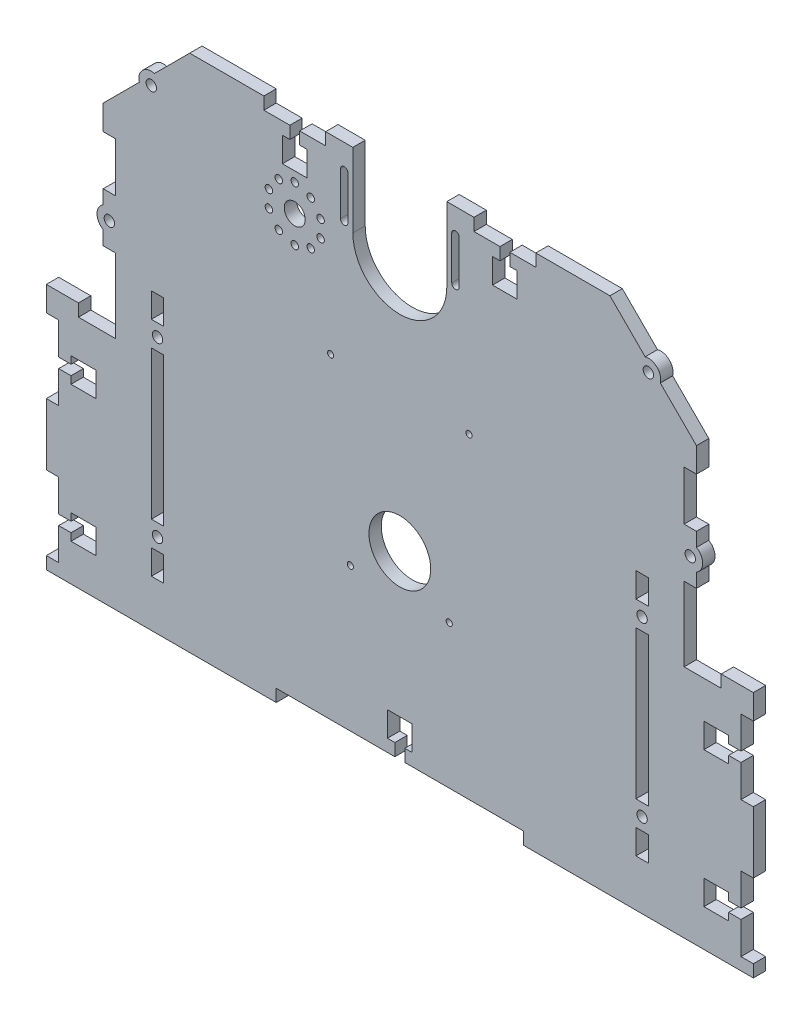
from build123d import *

# Parameters (mm, degrees)
SKETCH1_W           = 240
SKETCH1_H           = 210
BOSS_EXTRUDE1_DEPTH = 5
SKETCH2_W           = 5
SKETCH2_H           = 10
SKETCH2_H_2         = 60
CUT_EXTRUDE1_DEPTH  = 5
SKETCH3_W           = 5
SKETCH3_H           = 20
SKETCH3_H_2         = 25
CUT_EXTRUDE2_DEPTH  = 10
CUT_EXTRUDE3_DEPTH  = 10
SKETCH5_W           = 25
SKETCH5_H           = 5
CUT_EXTRUDE4_DEPTH  = 10
SKETCH7_R           = 2.1
CUT_EXTRUDE6_DEPTH  = 5
BOSS_EXTRUDE2_DEPTH = 5
SKETCH9_R           = 2.1
CUT_EXTRUDE7_DEPTH  = 5
SKETCH10_R          = 2.1
CUT_EXTRUDE8_DEPTH  = 5
BOSS_EXTRUDE3_DEPTH = 5
SKETCH13_R          = 2.1
CUT_EXTRUDE9_DEPTH  = 5
SKETCH14_R          = 1.25
CUT_EXTRUDE10_DEPTH = 5
SKETCH22_R          = 19
CUT_EXTRUDE16_DEPTH = 5
BOSS_EXTRUDE4_DEPTH = 5
SKETCH26_W          = 23
SKETCH26_H          = 100
BOSS_EXTRUDE5_DEPTH = 5
SKETCH27_W          = 5
SKETCH27_H          = 30
CUT_EXTRUDE19_DEPTH = 5
SKETCH29_W          = 5
SKETCH29_H          = 5
CUT_EXTRUDE20_DEPTH = 5
SKETCH31_W          = 10
SKETCH31_H          = 5
CUT_EXTRUDE21_DEPTH = 5
SKETCH32_W          = 286
SKETCH32_H          = 5
BOSS_EXTRUDE7_DEPTH = 1
SKETCH33_W          = 286
SKETCH33_H          = 5
CUT_EXTRUDE22_DEPTH = 1
SKETCH35_W          = 5
SKETCH35_H          = 4
CUT_EXTRUDE24_DEPTH = 5
SKETCH37_R          = 2.1
CUT_EXTRUDE25_DEPTH = 5
SKETCH38_R          = 2.1
BOSS_EXTRUDE8_DEPTH = 5
SKETCH39_W          = 4
SKETCH39_H          = 5
SKETCH39_W_2        = 10
SKETCH39_H_2        = 10
CUT_EXTRUDE26_DEPTH = 5
SKETCH40_W          = 100
SKETCH40_H          = 5
CUT_EXTRUDE27_DEPTH = 5
SKETCH41_R          = 2.1
SKETCH41_W          = 5
SKETCH41_H          = 10
SKETCH41_H_2        = 60
BOSS_EXTRUDE9_DEPTH = 5
CUT_EXTRUDE28_DEPTH = 5
SKETCH43_W          = 4
SKETCH43_H          = 5
CUT_EXTRUDE29_DEPTH = 5
SKETCH44_R          = 4.25
SKETCH44_R_2        = 1.5
CUT_EXTRUDE30_DEPTH = 10
SKETCH45_R          = 12.5
CUT_EXTRUDE31_DEPTH = 10


with BuildPart() as part:
    # Sketch1 → Boss-Extrude1 (new body)
    with BuildSketch(Plane.XY):
        with Locations((-120, 105)):
            Rectangle(SKETCH1_W, SKETCH1_H)
    extrude(amount=BOSS_EXTRUDE1_DEPTH)

    # Sketch2 → Cut-Extrude1 (cut)
    with BuildSketch(Plane.XY.offset(5)):
        with Locations((-218, 24)):
            Rectangle(SKETCH2_W, SKETCH2_H)
        with Locations((-218, 69)):
            Rectangle(SKETCH2_W, SKETCH2_H_2)
        with Locations((-218, 114)):
            Rectangle(SKETCH2_W, SKETCH2_H)
        with Locations((-203, 24)):
            Rectangle(SKETCH2_W, SKETCH2_H)
        with Locations((-203, 69)):
            Rectangle(SKETCH2_W, SKETCH2_H_2)
        with Locations((-203, 114)):
            Rectangle(SKETCH2_W, SKETCH2_H)
        with Locations((-37, 114)):
            Rectangle(SKETCH2_W, SKETCH2_H)
        with Locations((-37, 69)):
            Rectangle(SKETCH2_W, SKETCH2_H_2)
        with Locations((-37, 24)):
            Rectangle(SKETCH2_W, SKETCH2_H)
        with Locations((-22, 114)):
            Rectangle(SKETCH2_W, SKETCH2_H)
        with Locations((-22, 69)):
            Rectangle(SKETCH2_W, SKETCH2_H_2)
        with Locations((-22, 24)):
            Rectangle(SKETCH2_W, SKETCH2_H)
    extrude(amount=-CUT_EXTRUDE1_DEPTH, mode=Mode.SUBTRACT)

    # Sketch3 → Cut-Extrude2 (cut)
    with BuildSketch(Plane.XY.offset(5)):
        with Locations((-237.5, 195)):
            Rectangle(SKETCH3_W, SKETCH3_H)
        with Locations((-237.5, 155)):
            Rectangle(SKETCH3_W, SKETCH3_H)
        with Locations((-237.5, 112.5)):
            Rectangle(SKETCH3_W, SKETCH3_H_2)
        with Locations((-2.5, 112.5)):
            Rectangle(SKETCH3_W, SKETCH3_H_2)
        with Locations((-2.5, 155)):
            Rectangle(SKETCH3_W, SKETCH3_H)
        with Locations((-2.5, 195)):
            Rectangle(SKETCH3_W, SKETCH3_H)
    extrude(amount=-CUT_EXTRUDE2_DEPTH, mode=Mode.SUBTRACT)

    # Sketch4 → Cut-Extrude3 (cut)
    with BuildSketch(Plane.XY.offset(5)):
        Polygon((-235, 180), (-240, 175), (-240, 210), (-205, 210), (-210, 205), (-235, 205), align=None)
        Polygon((-235, 205), (-235, 180), (-210, 205), align=None)
        Polygon((-30, 205), (-5, 205), (-5, 180), align=None)
        Polygon((-30, 205), (-35, 210), (0, 210), (0, 175), (-5, 180), (-5, 205), align=None)
    extrude(amount=-CUT_EXTRUDE3_DEPTH, mode=Mode.SUBTRACT)

    # Sketch5 → Cut-Extrude4 (cut)
    with BuildSketch(Plane.XY.offset(5)):
        with Locations((-162.5, 207.5)):
            Rectangle(SKETCH5_W, SKETCH5_H)
        with Locations((-77.5, 207.5)):
            Rectangle(SKETCH5_W, SKETCH5_H)
    extrude(amount=-CUT_EXTRUDE4_DEPTH, mode=Mode.SUBTRACT)

    # Sketch7 → Cut-Extrude6 (cut)
    with BuildSketch(Plane.XY.offset(5)):
        with Locations((-203, 34)):
            Circle(SKETCH7_R)
        with Locations((-218, 34)):
            Circle(SKETCH7_R)
        with Locations((-203, 104)):
            Circle(SKETCH7_R)
        with Locations((-218, 104)):
            Circle(SKETCH7_R)
        with Locations((-22, 104)):
            Circle(SKETCH7_R)
        with Locations((-37, 104)):
            Circle(SKETCH7_R)
        with Locations((-22, 34)):
            Circle(SKETCH7_R)
        with Locations((-37, 34)):
            Circle(SKETCH7_R)
    extrude(amount=-CUT_EXTRUDE6_DEPTH, mode=Mode.SUBTRACT)

    # Sketch8 → Boss-Extrude2 (add)
    with BuildSketch(Plane.XY.offset(5)):
        with BuildLine():
            Line((-124.330127019, 210), (-115.669872981, 210))
            ThreePointArc((-115.669872981, 210), (-120, 212.5), (-124.330127019, 210))
        make_face()
        with BuildLine():
            Line((-54.330127019, 210), (-45.669872981, 210))
            ThreePointArc((-45.669872981, 210), (-50, 212.5), (-54.330127019, 210))
        make_face()
        with BuildLine():
            Line((-194.330127019, 210), (-185.669872981, 210))
            ThreePointArc((-185.669872981, 210), (-190, 212.5), (-194.330127019, 210))
        make_face()
    extrude(amount=-BOSS_EXTRUDE2_DEPTH)

    # Sketch9 → Cut-Extrude7 (cut)
    with BuildSketch(Plane.XY.offset(5)):
        with Locations((-50, 207.5)):
            Circle(SKETCH9_R)
        with Locations((-120, 207.5)):
            Circle(SKETCH9_R)
        with Locations((-190, 207.5)):
            Circle(SKETCH9_R)
    extrude(amount=-CUT_EXTRUDE7_DEPTH, mode=Mode.SUBTRACT)

    # Sketch10 → Cut-Extrude8 (cut)
    with BuildSketch(Plane.XY.offset(5)):
        with Locations((-220.537196828, 190.927269266)):
            Circle(SKETCH10_R)
        with Locations((-19.462803172, 190.927269266)):
            Circle(SKETCH10_R)
    extrude(amount=-CUT_EXTRUDE8_DEPTH, mode=Mode.SUBTRACT)

    # Sketch11 → Boss-Extrude3 (add)
    with BuildSketch(Plane.XY.offset(5)):
        with BuildLine():
            Line((-219.243101602, 195.756898398), (-225.366825959, 189.633174041))
            ThreePointArc((-225.366825959, 189.633174041), (-224.072730734, 194.462803172), (-219.243101602, 195.756898398))
        make_face()
        with BuildLine():
            Line((-20.756898398, 195.756898398), (-14.633174041, 189.633174041))
            ThreePointArc((-14.633174041, 189.633174041), (-15.927269266, 194.462803172), (-20.756898398, 195.756898398))
        make_face()
    extrude(amount=-BOSS_EXTRUDE3_DEPTH)

    # Sketch13 → Cut-Extrude9 (cut)
    with BuildSketch(Plane.XY.offset(5)):
        with Locations((-237.5, 135)):
            Circle(SKETCH13_R)
        with Locations((-2.5, 135)):
            Circle(SKETCH13_R)
    extrude(amount=-CUT_EXTRUDE9_DEPTH, mode=Mode.SUBTRACT)

    # Sketch14 → Cut-Extrude10 (cut)
    with BuildSketch(Plane.XY.offset(5)):
        with Locations((-92, 133)):
            Circle(SKETCH14_R)
        with Locations((-100, 63)):
            Circle(SKETCH14_R)
        with Locations((-148, 133)):
            Circle(SKETCH14_R)
        with Locations((-140, 63)):
            Circle(SKETCH14_R)
    extrude(amount=-CUT_EXTRUDE10_DEPTH, mode=Mode.SUBTRACT)

    # Sketch22 → Cut-Extrude16 (cut)
    with BuildSketch(Plane.XY.offset(5)):
        with Locations((-120, 180)):
            Circle(SKETCH22_R)
    extrude(amount=-CUT_EXTRUDE16_DEPTH, mode=Mode.SUBTRACT)

    # Sketch23 → Boss-Extrude4 (add)
    with BuildSketch(Plane.XY.offset(5)):
        with BuildLine():
            Line((-240, 130.669872981), (-240, 139.330127019))
            ThreePointArc((-240, 139.330127019), (-242.5, 135), (-240, 130.669872981))
        make_face()
        with BuildLine():
            Line((0, 130.669872981), (0, 139.330127019))
            ThreePointArc((0, 139.330127019), (2.5, 135), (0, 130.669872981))
        make_face()
    extrude(amount=-BOSS_EXTRUDE4_DEPTH)

    # Sketch26 → Boss-Extrude5 (add)
    with BuildSketch(Plane.XY.offset(5)):
        with Locations((11.5, 50)):
            Rectangle(SKETCH26_W, SKETCH26_H)
        with Locations((-251.5, 50)):
            Rectangle(SKETCH26_W, SKETCH26_H)
    extrude(amount=-BOSS_EXTRUDE5_DEPTH)

    # Sketch27 → Cut-Extrude19 (cut)
    with BuildSketch(Plane.XY.offset(5)):
        with Locations((-260.5, 75)):
            Rectangle(SKETCH27_W, SKETCH27_H)
        with Locations((-260.5, 20)):
            Rectangle(SKETCH27_W, SKETCH27_H)
        with Locations((20.5, 75)):
            Rectangle(SKETCH27_W, SKETCH27_H)
        with Locations((20.5, 20)):
            Rectangle(SKETCH27_W, SKETCH27_H)
    extrude(amount=-CUT_EXTRUDE19_DEPTH, mode=Mode.SUBTRACT)

    # Sketch29 → Cut-Extrude20 (cut)
    with BuildSketch(Plane.XY.offset(5)):
        with Locations((-237.5, 97.5)):
            Rectangle(SKETCH29_W, SKETCH29_H)
        with Locations((-2.5, 97.5)):
            Rectangle(SKETCH29_W, SKETCH29_H)
    extrude(amount=-CUT_EXTRUDE20_DEPTH, mode=Mode.SUBTRACT)

    # Sketch31 → Cut-Extrude21 (cut)
    with BuildSketch(Plane(origin=(0, 100, 0), x_dir=(1, 0, 0), z_dir=(0, 1, 0))):
        with Locations((-245, -2.5)):
            Rectangle(SKETCH31_W, SKETCH31_H)
    cut_extrude21 = extrude(amount=-CUT_EXTRUDE21_DEPTH, mode=Mode.SUBTRACT)

    # Mirror2: Cut-Extrude21 across plane
    add(cut_extrude21.mirror(Plane.ZY.offset(120)), mode=Mode.SUBTRACT)

    # Sketch32 → Boss-Extrude7 (add)
    with BuildSketch(Plane.XZ):
        with Locations((-120, 2.5)):
            Rectangle(SKETCH32_W, SKETCH32_H)
    extrude(amount=BOSS_EXTRUDE7_DEPTH)

    # Sketch33 → Cut-Extrude22 (cut)
    with BuildSketch(Plane.XZ.offset(1)):
        with Locations((-120, 2.5)):
            Rectangle(SKETCH33_W, SKETCH33_H)
    extrude(amount=-CUT_EXTRUDE22_DEPTH, mode=Mode.SUBTRACT)

    # Sketch35 → Cut-Extrude24 (cut)
    with BuildSketch(Plane.XY.offset(5)):
        with Locations((15.5, 20)):
            Rectangle(SKETCH35_W, SKETCH35_H)
        with Locations((15.5, 75)):
            Rectangle(SKETCH35_W, SKETCH35_H)
        with Locations((-255.5, 20)):
            Rectangle(SKETCH35_W, SKETCH35_H)
        with Locations((-255.5, 75)):
            Rectangle(SKETCH35_W, SKETCH35_H)
        Polygon((13, 15), (13, 18), (13, 22), (13, 25), (3, 25), (3, 15), align=None)
        Polygon((13, 80), (3, 80), (3, 70), (13, 70), (13, 73), (13, 77), align=None)
        Polygon((-253, 15), (-243, 15), (-243, 25), (-253, 25), (-253, 22), (-253, 18), align=None)
        Polygon((-253, 80), (-253, 77), (-253, 73), (-253, 70), (-243, 70), (-243, 80), align=None)
    extrude(amount=-CUT_EXTRUDE24_DEPTH, mode=Mode.SUBTRACT)

    # Sketch37 → Cut-Extrude25 (cut)
    with BuildSketch(Plane.XY.offset(5)):
        with Locations((-190, 207.5)):
            Circle(SKETCH37_R)
        with Locations((-120, 207.5)):
            Circle(SKETCH37_R)
        with Locations((-50, 207.5)):
            Circle(SKETCH37_R)
        with BuildLine():
            Line((-194.330127019, 210), (-185.669872981, 210))
            ThreePointArc((-185.669872981, 210), (-190, 212.5), (-194.330127019, 210))
        make_face()
        with BuildLine():
            Line((-124.330127019, 210), (-115.669872981, 210))
            ThreePointArc((-115.669872981, 210), (-120, 212.5), (-124.330127019, 210))
        make_face()
        with BuildLine():
            Line((-54.330127019, 210), (-45.669872981, 210))
            ThreePointArc((-45.669872981, 210), (-50, 212.5), (-54.330127019, 210))
        make_face()
    extrude(amount=-CUT_EXTRUDE25_DEPTH, mode=Mode.SUBTRACT)

    # Sketch38 → Boss-Extrude8 (add)
    with BuildSketch(Plane.XY.offset(5)):
        with Locations((-190, 207.5)):
            Circle(SKETCH38_R)
        with Locations((-120, 207.5)):
            Circle(SKETCH38_R)
        with Locations((-50, 207.5)):
            Circle(SKETCH38_R)
    extrude(amount=-BOSS_EXTRUDE8_DEPTH)

    # Sketch39 → Cut-Extrude26 (cut)
    with BuildSketch(Plane.XY.offset(5)):
        with Locations((-162.5, 202.5)):
            Rectangle(SKETCH39_W, SKETCH39_H)
        with Locations((-162.5, 195)):
            Rectangle(SKETCH39_W_2, SKETCH39_H_2)
        with Locations((-77.5, 195)):
            Rectangle(SKETCH39_W_2, SKETCH39_H_2)
        with Locations((-77.5, 202.5)):
            Rectangle(SKETCH39_W, SKETCH39_H)
    extrude(amount=-CUT_EXTRUDE26_DEPTH, mode=Mode.SUBTRACT)

    # Sketch40 → Cut-Extrude27 (cut)
    with BuildSketch(Plane.XZ):
        with Locations((-120, 2.5)):
            Rectangle(SKETCH40_W, SKETCH40_H)
    extrude(amount=-CUT_EXTRUDE27_DEPTH, mode=Mode.SUBTRACT)

    # Sketch41 → Boss-Extrude9 (add)
    with BuildSketch(Plane.XY.offset(5)):
        with Locations((-37, 34)):
            Circle(SKETCH41_R)
        with Locations((-37, 104)):
            Circle(SKETCH41_R)
        with Locations((-203, 104)):
            Circle(SKETCH41_R)
        with Locations((-203, 34)):
            Circle(SKETCH41_R)
        with Locations((-37, 24)):
            Rectangle(SKETCH41_W, SKETCH41_H)
        with Locations((-37, 69)):
            Rectangle(SKETCH41_W, SKETCH41_H_2)
        with Locations((-37, 114)):
            Rectangle(SKETCH41_W, SKETCH41_H)
        with Locations((-203, 114)):
            Rectangle(SKETCH41_W, SKETCH41_H)
        with Locations((-203, 69)):
            Rectangle(SKETCH41_W, SKETCH41_H_2)
        with Locations((-203, 24)):
            Rectangle(SKETCH41_W, SKETCH41_H)
    extrude(amount=-BOSS_EXTRUDE9_DEPTH)

    # Sketch42 → Cut-Extrude28 (cut)
    with BuildSketch(Plane.XY.offset(5)):
        with BuildLine():
            Line((-139, 180), (-139, 210))
            Line((-139, 210), (-101, 210))
            Line((-101, 210), (-101, 180))
            ThreePointArc((-101, 180), (-120, 199), (-139, 180))
        make_face()
    extrude(amount=-CUT_EXTRUDE28_DEPTH, mode=Mode.SUBTRACT)

    # Sketch43 → Cut-Extrude29 (cut)
    with BuildSketch(Plane.XY.offset(5)):
        Polygon((-125, 10), (-122, 10), (-118, 10), (-115, 10), (-115, 20), (-125, 20), align=None)
        with Locations((-120, 7.5)):
            Rectangle(SKETCH43_W, SKETCH43_H)
    extrude(amount=-CUT_EXTRUDE29_DEPTH, mode=Mode.SUBTRACT)

    # Sketch44 → Cut-Extrude30 (cut)
    with BuildSketch(Plane.XY.offset(5)):
        with BuildLine():
            ThreePointArc((-99, 182.5), (-97.5, 184), (-96, 182.5))
            Line((-96, 182.5), (-96, 200))
            ThreePointArc((-96, 200), (-97.5, 198.5), (-99, 200))
            Line((-99, 200), (-99, 182.5))
        make_face()
        with BuildLine():
            ThreePointArc((-99, 182.5), (-97.5, 181), (-96, 182.5))
            Line((-96, 182.5), (-99, 182.5))
        make_face()
        with BuildLine():
            Line((-99, 182.5), (-96, 182.5))
            ThreePointArc((-96, 182.5), (-97.5, 184), (-99, 182.5))
        make_face()
        with BuildLine():
            ThreePointArc((-99, 200), (-97.5, 198.5), (-96, 200))
            Line((-96, 200), (-99, 200))
        make_face()
        with BuildLine():
            Line((-99, 200), (-96, 200))
            ThreePointArc((-96, 200), (-97.5, 201.5), (-99, 200))
        make_face()
        with BuildLine():
            ThreePointArc((-144, 182.5), (-142.5, 181), (-141, 182.5))
            Line((-141, 182.5), (-144, 182.5))
        make_face()
        with BuildLine():
            Line((-144, 182.5), (-141, 182.5))
            ThreePointArc((-141, 182.5), (-142.5, 184), (-144, 182.5))
        make_face()
        with BuildLine():
            ThreePointArc((-144, 182.5), (-142.5, 184), (-141, 182.5))
            Line((-141, 182.5), (-141, 200))
            ThreePointArc((-141, 200), (-142.5, 198.5), (-144, 200))
            Line((-144, 200), (-144, 182.5))
        make_face()
        with BuildLine():
            ThreePointArc((-144, 200), (-142.5, 198.5), (-141, 200))
            Line((-141, 200), (-144, 200))
        make_face()
        with BuildLine():
            Line((-144, 200), (-141, 200))
            ThreePointArc((-141, 200), (-142.5, 201.5), (-144, 200))
        make_face()
        with Locations((-162.5, 175)):
            Circle(SKETCH44_R)
        with Locations((-156.034362225, 183.899186938)):
            Circle(SKETCH44_R_2)
        with Locations((-152.038378321, 178.399186938)):
            Circle(SKETCH44_R_2)
        with Locations((-152.038378321, 171.600813062)):
            Circle(SKETCH44_R_2)
        with Locations((-156.034362225, 166.100813062)):
            Circle(SKETCH44_R_2)
        with Locations((-162.5, 164)):
            Circle(SKETCH44_R_2)
        with Locations((-168.965637775, 166.100813062)):
            Circle(SKETCH44_R_2)
        with Locations((-172.961621679, 171.600813062)):
            Circle(SKETCH44_R_2)
        with Locations((-172.961621679, 178.399186938)):
            Circle(SKETCH44_R_2)
        with Locations((-168.965637775, 183.899186938)):
            Circle(SKETCH44_R_2)
        with Locations((-162.5, 186)):
            Circle(SKETCH44_R_2)
    extrude(amount=-CUT_EXTRUDE30_DEPTH, mode=Mode.SUBTRACT)

    # Sketch45 → Cut-Extrude31 (cut)
    with BuildSketch(Plane.XY.offset(5)):
        with Locations((-120, 78)):
            Circle(SKETCH45_R)
    extrude(amount=-CUT_EXTRUDE31_DEPTH, mode=Mode.SUBTRACT)


solid = part.part
